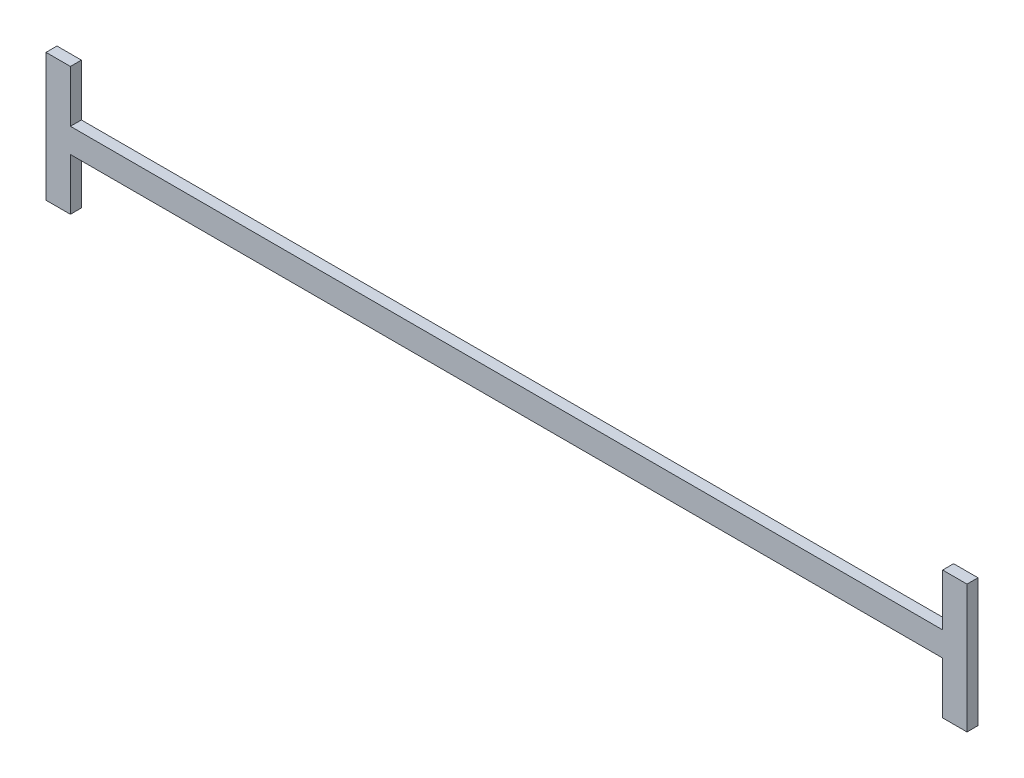
from build123d import *

# Parameters (mm, degrees)
SALIENTE_EXTRUIR1_DEPTH = 1.8


with BuildPart() as part:
    # Croquis1 → Saliente-Extruir1 (new body)
    with BuildSketch(Plane.XY):
        Polygon((71.5, 0), (-71.5, 0), (-71.5, -8.5), (-75.5, -8.5), (-75.5, 12.5), (-71.5, 12.5), (-71.5, 4), (71.5, 4), (71.5, 12.5), (75.5, 12.5), (75.5, -8.5), (71.5, -8.5), align=None)
    extrude(amount=SALIENTE_EXTRUIR1_DEPTH)


solid = part.part
